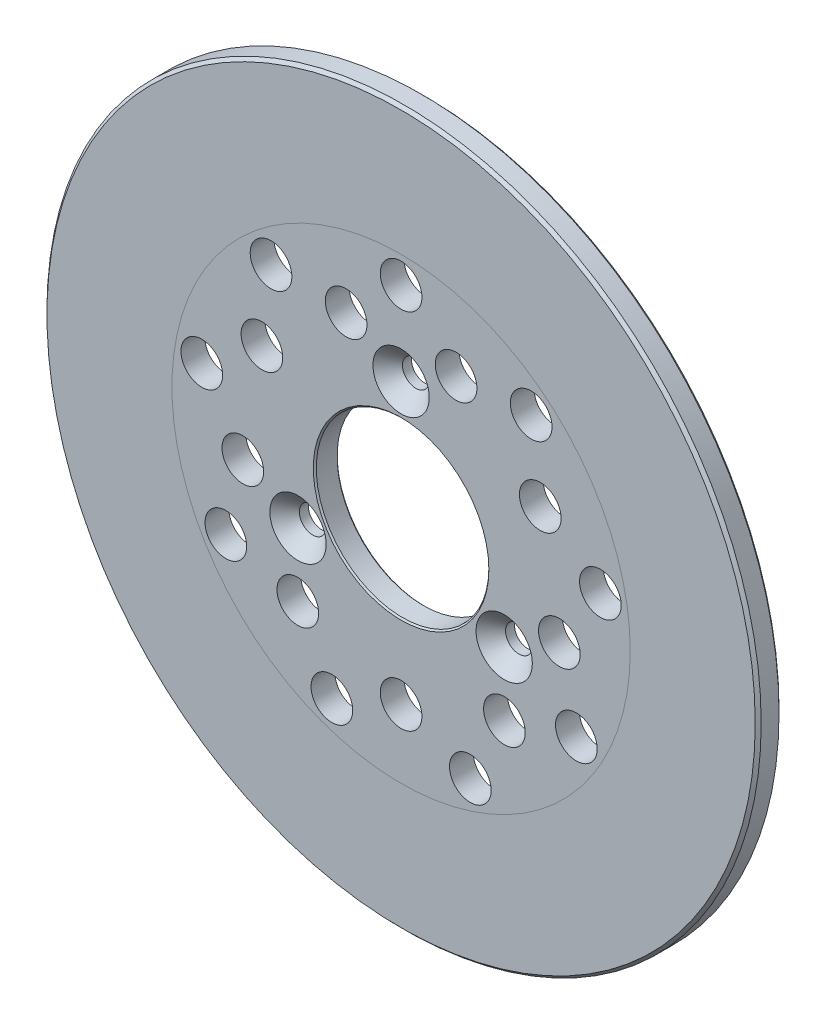
from build123d import *

# Parameters (mm, degrees)
SKICA1_R                                          = 120
SKICA1_R_2                                        = 29
P_IDAT_VYSUNUT_M1_DEPTH                           = 8
KU_ELOV_ZAHLOUBEN_PRO_M8_ROUBY_S_Z_PU_D           = 9
KU_ELOV_ZAHLOUBEN_PRO_M8_ROUBY_S_Z_PU_DEPTH       = 8
KU_ELOV_ZAHLOUBEN_PRO_M8_ROUBY_S_Z_PU_CSINK_D     = 18.92
KU_ELOV_ZAHLOUBEN_PRO_M8_ROUBY_S_Z_PU_CSINK_ANGLE = 90
KU_ELOV_ZAHLOUBEN_PRO_M8_ROUBY_S_Z_PU_TIP         = 2.703872786
ZKOSEN_1_SIZE                                     = 0.5
ZKOSEN_2_SIZE                                     = 0.5
SKICA4_R                                          = 7
ODEBRAT_VYSUNUT_M1_DEPTH                          = 170.894084653
KRUHOV_POLE1_COUNT                                = 9
ZKOSEN_3_SIZE                                     = 1
SKICA6_R                                          = 7
ODEBRAT_VYSUNUT_M2_DEPTH                          = 170.894084653
KRUHOV_POLE2_COUNT                                = 9


with BuildPart() as part:
    # Skica1 → Přidat vysunutím1 (new body)
    with BuildSketch(Plane.XY):
        Circle(SKICA1_R)
        Circle(SKICA1_R_2, mode=Mode.SUBTRACT)
    extrude(amount=P_IDAT_VYSUNUT_M1_DEPTH)

    # Kuželové zahloubení pro M8 šrouby s zápustnou hlavou s vnitřním šestihranem1
    with Locations(Plane.XY.offset(8)):
        with Locations((0, 40), (34.641016151, -20), (-34.641016151, -20)):
            CounterSinkHole(KU_ELOV_ZAHLOUBEN_PRO_M8_ROUBY_S_Z_PU_D / 2, KU_ELOV_ZAHLOUBEN_PRO_M8_ROUBY_S_Z_PU_CSINK_D / 2, depth=KU_ELOV_ZAHLOUBEN_PRO_M8_ROUBY_S_Z_PU_DEPTH, counter_sink_angle=KU_ELOV_ZAHLOUBEN_PRO_M8_ROUBY_S_Z_PU_CSINK_ANGLE)
            with Locations((0, 0, -(KU_ELOV_ZAHLOUBEN_PRO_M8_ROUBY_S_Z_PU_DEPTH + KU_ELOV_ZAHLOUBEN_PRO_M8_ROUBY_S_Z_PU_TIP / 2))):  # 118° drill point
                Cone(0, KU_ELOV_ZAHLOUBEN_PRO_M8_ROUBY_S_Z_PU_D / 2, KU_ELOV_ZAHLOUBEN_PRO_M8_ROUBY_S_Z_PU_TIP, mode=Mode.SUBTRACT)

    # Zkosení1
    zkosen_1_edges = [part.edges().sort_by_distance(p)[0] for p in [
        (-29, 0, 0),
    ]]
    chamfer(zkosen_1_edges, length=ZKOSEN_1_SIZE)

    # Zkosení2
    zkosen_2_edges = [part.edges().sort_by_distance(p)[0] for p in [
        (-29, 0, 8),
    ]]
    chamfer(zkosen_2_edges, length=ZKOSEN_2_SIZE)

    # Skica4 → Odebrat vysunutím1 (cut, through all)
    with BuildSketch(Plane.XY.offset(8)):
        with Locations((18.46908774, 50.743401522)):
            Circle(SKICA4_R)
    odebrat_vysunut_m1 = extrude(amount=-ODEBRAT_VYSUNUT_M1_DEPTH, mode=Mode.SUBTRACT)

    # Kruhové pole1: Odebrat vysunutím1 ×9 about axis
    kruhov_pole1_axis = Axis((0, 0, 7.5), (0, 0, -1))
    for i in range(1, KRUHOV_POLE1_COUNT):
        add(odebrat_vysunut_m1.rotate(kruhov_pole1_axis, i * 360 / KRUHOV_POLE1_COUNT), mode=Mode.SUBTRACT)

    # Zkosení3
    zkosen_3_edges = [part.edges().sort_by_distance(p)[0] for p in [
        (-120, 0, 0),
        (-120, 0, 8),
    ]]
    chamfer(zkosen_3_edges, length=ZKOSEN_3_SIZE)

    # Skica6 → Odebrat vysunutím2 (cut, through all)
    with BuildSketch(Plane.XY.offset(8)):
        with Locations((0, 68)):
            Circle(SKICA6_R)
    odebrat_vysunut_m2 = extrude(amount=-ODEBRAT_VYSUNUT_M2_DEPTH, mode=Mode.SUBTRACT)

    # Kruhové pole2: Odebrat vysunutím2 ×9 about axis
    kruhov_pole2_axis = Axis((0, 0, 7.5), (0, 0, -1))
    for i in range(1, KRUHOV_POLE2_COUNT):
        add(odebrat_vysunut_m2.rotate(kruhov_pole2_axis, i * 360 / KRUHOV_POLE2_COUNT), mode=Mode.SUBTRACT)


solid = part.part
